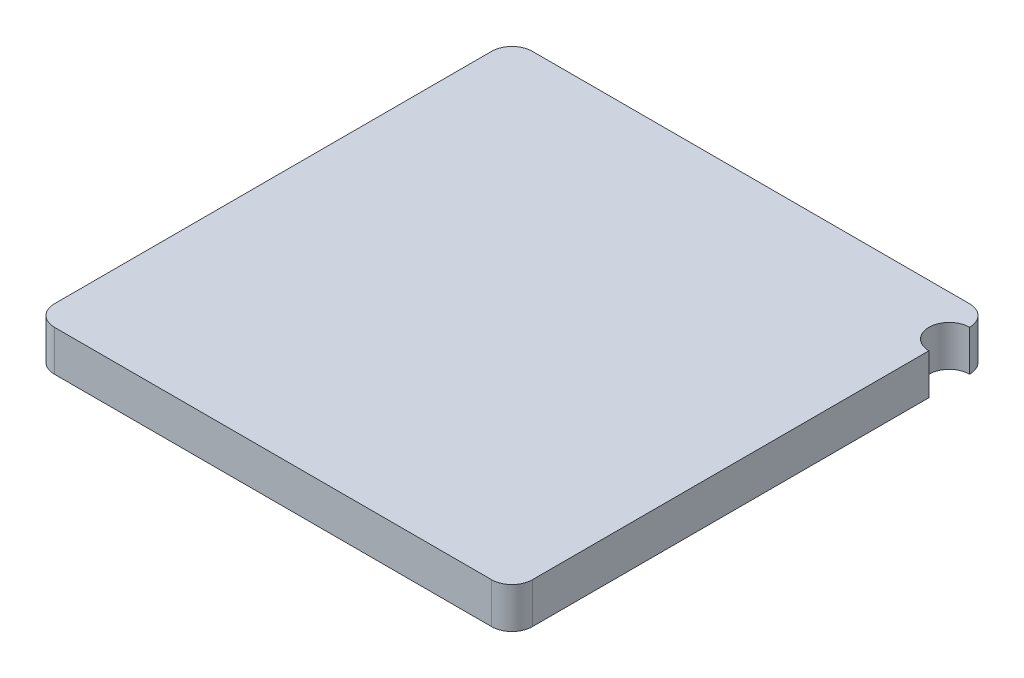
from build123d import *

# Parameters (mm, degrees)
SKETCH1_W           = 2.35
SKETCH1_H           = 2.35
BOSS_EXTRUDE1_DEPTH = 0.2
FILLET1_R           = 0.1
SKETCH2_R           = 0.1
CUT_EXTRUDE1_DEPTH  = 1.2


with BuildPart() as part:
    # Sketch1 → Boss-Extrude1 (new body)
    with BuildSketch(Plane(origin=(0, 0, 0), x_dir=(1, 0, 0), z_dir=(0, 1, 0))):
        Rectangle(SKETCH1_W, SKETCH1_H)
    extrude(amount=BOSS_EXTRUDE1_DEPTH)

    # Fillet1
    fillet1_edges = [part.edges().sort_by_distance(p)[0] for p in [
        (1.175, 0.1, 1.175),
        (-1.175, 0.1, 1.175),
        (-1.175, 0.1, -1.175),
        (1.175, 0.1, -1.175),
    ]]
    fillet(fillet1_edges, radius=FILLET1_R)

    # Sketch2 → Cut-Extrude1 (cut, through all)
    with BuildSketch(Plane(origin=(0, 0.2, 0), x_dir=(1, 0, 0), z_dir=(0, 1, 0))):
        with Locations((1.175, 0.975)):
            Circle(SKETCH2_R)
    extrude(amount=-CUT_EXTRUDE1_DEPTH, mode=Mode.SUBTRACT)


solid = part.part
